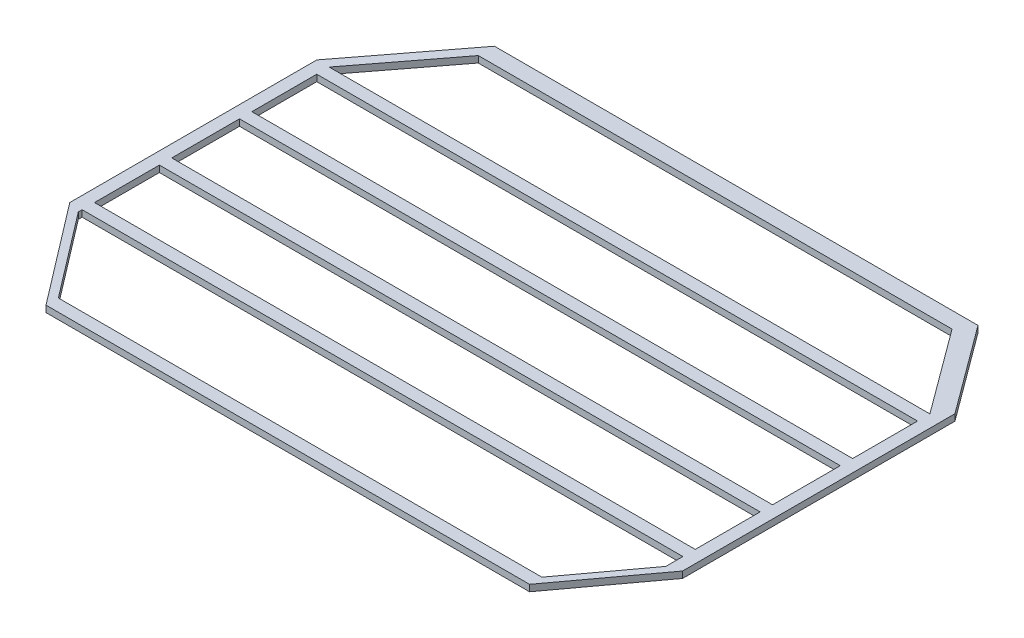
from build123d import *

# Parameters (mm, degrees)
BOSS_EXTRUDE1_DEPTH = 10
CUT_EXTRUDE1_DEPTH  = 10
BOSS_EXTRUDE3_START = -20
SKETCH7_W           = 80
SKETCH7_H           = 80
BOSS_EXTRUDE3_DEPTH = 30
SKETCH8_W           = 925.61
SKETCH8_H           = 100
SKETCH8_H_2         = 104.39
SKETCH8_W_2         = 80
SKETCH8_H_3         = 80
CUT_EXTRUDE6_DEPTH  = 10


with BuildPart() as part:
    # Sketch2 → Boss-Extrude1 (new body)
    with BuildSketch(Plane(origin=(0, 0, 0), x_dir=(1, 0, 0), z_dir=(0, 1, 0))):
        Polygon((118.58, 345.487717935), (863.58, 345.487717935), (963.71, 209.828898833), (963.71, -209.828898833), (863.58, -345.487717935), (118.58, -345.487717935), (0, -190.295), (0, 190.295), align=None)
    extrude(amount=BOSS_EXTRUDE1_DEPTH)

    # Sketch3 → Cut-Extrude1 (cut)
    with BuildSketch(Plane(origin=(0, 10, 0), x_dir=(1, 0, 0), z_dir=(0, 1, 0))):
        with BuildLine():
            Line((340, -245.487717935), (340, -279.772016162))
            Line((340, -279.772016162), (341.671796469, -281.959995904))
            ThreePointArc((341.671796469, -281.959995904), (371.660256421, -306.647976918), (409.484364019, -315.487717935))
            Line((409.484364019, -315.487717935), (542.385502063, -315.487717935))
            Line((542.385502063, -315.487717935), (542.385502063, -245.487717935))
            Line((542.385502063, -245.487717935), (340, -245.487717935))
        make_face()
    cut_extrude1 = extrude(amount=-CUT_EXTRUDE1_DEPTH, mode=Mode.SUBTRACT)

    # Sketch7 → Boss-Extrude3 (add)
    with BuildSketch(Plane(origin=(0, 10, 0), x_dir=(1, 0, 0), z_dir=(0, 1, 0)).offset(BOSS_EXTRUDE3_START)):
        with Locations((89.309431631, -0.676064103)):
            Rectangle(SKETCH7_W, SKETCH7_H)
    boss_extrude3 = extrude(amount=BOSS_EXTRUDE3_DEPTH)

    # Mirror2: Boss-Extrude3 across plane
    add(boss_extrude3.mirror(Plane.ZY.offset(-481.855)))

    # Mirror3: Cut-Extrude1 across plane
    add(cut_extrude1.mirror(Plane.XY), mode=Mode.SUBTRACT)

    # Sketch8 → Cut-Extrude6 (cut)
    with BuildSketch(Plane(origin=(0, 10, 0), x_dir=(1, 0, 0), z_dir=(0, 1, 0))):
        Polygon((848.514252318, 320.555846821), (118.58, 320.555846821), (19.05, 190.295), (944.66, 190.295), align=None)
        with BuildLine():
            Line((409.484364019, 315.487717935), (542.385502063, 315.487717935))
            Line((542.385502063, 315.487717935), (542.385502063, 245.487717935))
            Line((542.385502063, 245.487717935), (340, 245.487717935))
            Line((340, 245.487717935), (340, 279.772016162))
            Line((340, 279.772016162), (341.671796469, 281.959995904))
            ThreePointArc((341.671796469, 281.959995904), (371.660256421, 306.647976918), (409.484364019, 315.487717935))
        make_face(mode=Mode.SUBTRACT)
        with Locations((481.855, 121.245)):
            Rectangle(SKETCH8_W, SKETCH8_H)
        with Locations((481.855, 0)):
            Rectangle(SKETCH8_W, SKETCH8_H_2)
        with Locations((89.309431631, -0.676064103)):
            Rectangle(SKETCH8_W_2, SKETCH8_H_3, mode=Mode.SUBTRACT)
        with Locations((874.400568369, -0.676064103)):
            Rectangle(SKETCH8_W_2, SKETCH8_H_3, mode=Mode.SUBTRACT)
        with Locations((481.855, -121.245)):
            Rectangle(SKETCH8_W, SKETCH8_H)
        Polygon((944.66, -190.295), (19.05, -190.295), (19.05, -196.176871114), (118.58, -326.437717935), (863.58, -326.437717935), (944.66, -216.588351584), align=None)
        with BuildLine():
            Line((340, -279.772016162), (340, -245.487717935))
            Line((340, -245.487717935), (542.385502063, -245.487717935))
            Line((542.385502063, -245.487717935), (542.385502063, -315.487717935))
            Line((542.385502063, -315.487717935), (409.484364019, -315.487717935))
            ThreePointArc((409.484364019, -315.487717935), (371.660256421, -306.647976918), (341.671796469, -281.959995904))
            Line((341.671796469, -281.959995904), (340, -279.772016162))
        make_face(mode=Mode.SUBTRACT)
    extrude(amount=-CUT_EXTRUDE6_DEPTH, mode=Mode.SUBTRACT)


with BuildPart() as body_2:
    # of the pieces the cut leaves, the one that is kept (cut_extrude6_keep)
    add(part.part.solids().sort_by_distance((118.58, 0, -345.487717935))[0])


solid = body_2.part
